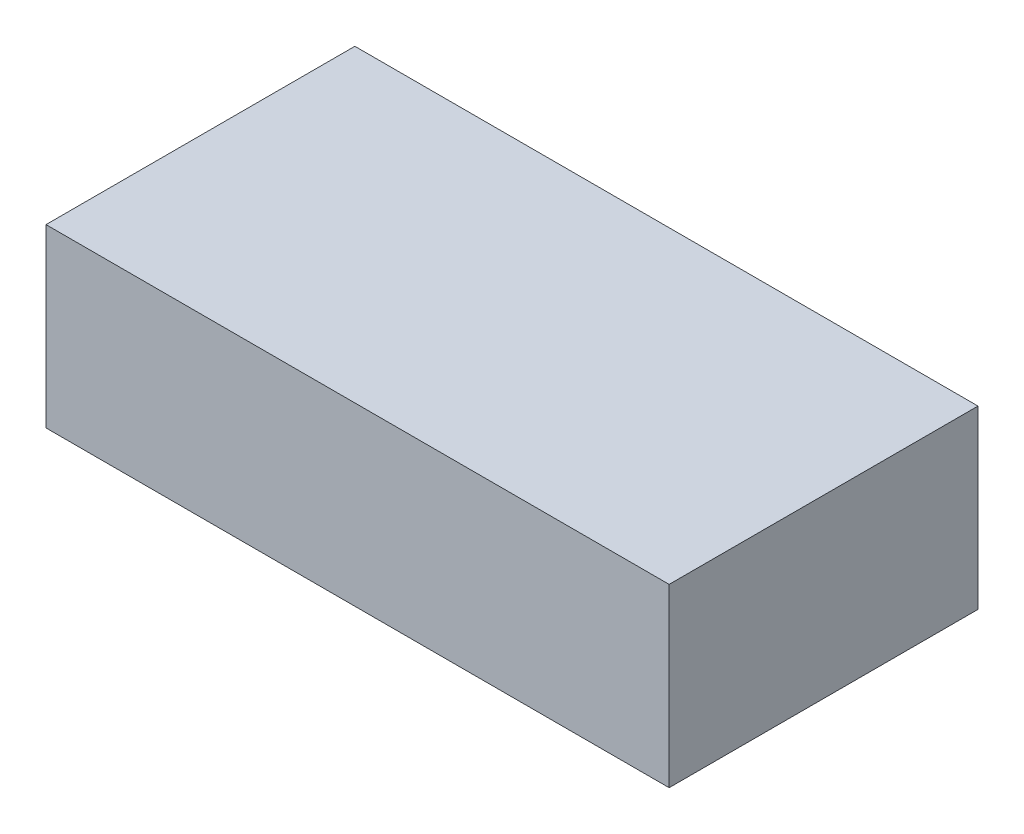
from build123d import *

# Parameters (mm, degrees)
SKETCH_1_W      = 230
SKETCH_1_H      = 114
EXTRUDE_1_DEPTH = 65


with BuildPart() as part:
    # Эскиз1 → Бобышка-Вытянуть1 (new body)
    with BuildSketch(Plane(origin=(0, 0, 0), x_dir=(1, 0, 0), z_dir=(0, 1, 0))):
        with Locations((115, 57)):
            Rectangle(SKETCH_1_W, SKETCH_1_H)
    extrude(amount=EXTRUDE_1_DEPTH)


solid = part.part
